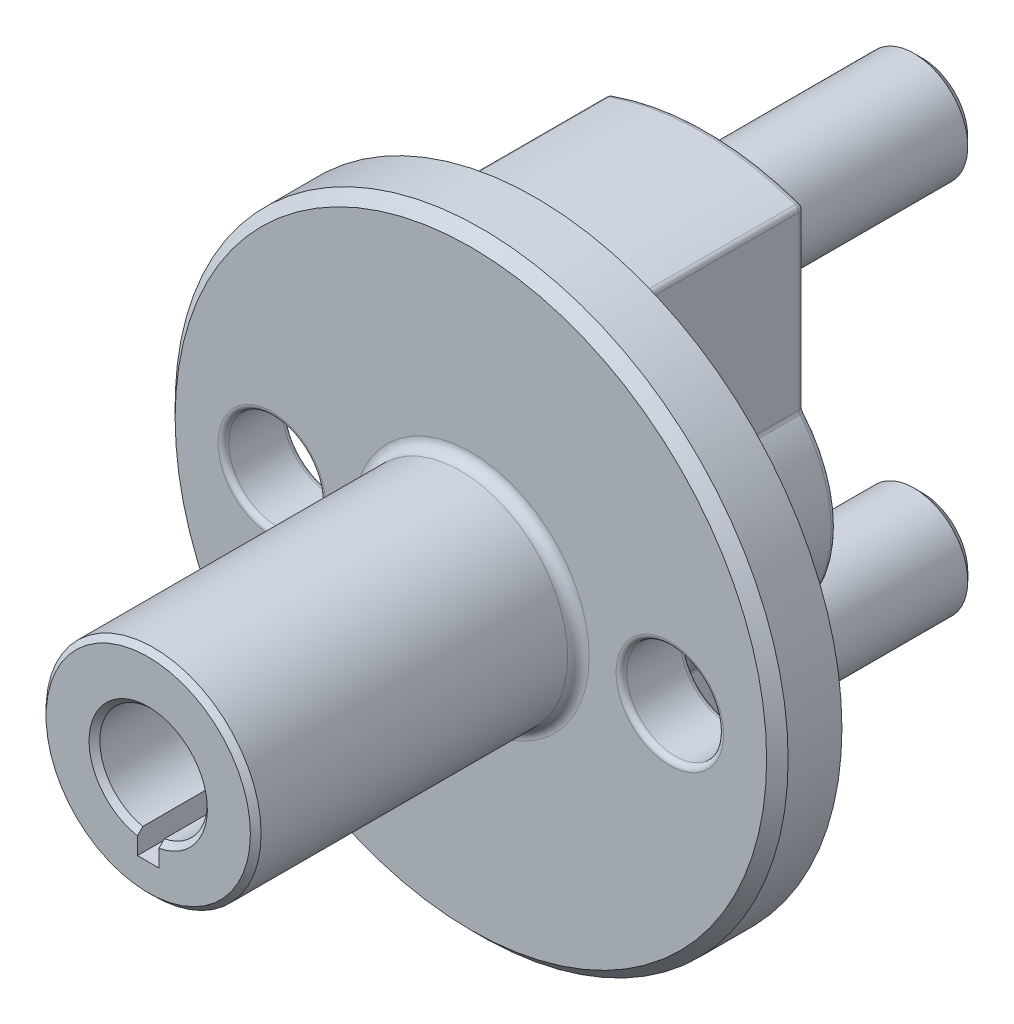
from build123d import *

# Parameters (mm, degrees)
SKETCH1_R           = 28.5
BOSS_EXTRUDE1_DEPTH = 6
BOSS_EXTRUDE2_DEPTH = 16
CHAMFER1_SIZE       = 1
FILLET1_R           = 0.5
SKETCH4_R           = 4.5
CUT_EXTRUDE1_DEPTH  = 23.0000001
FILLET2_R           = 0.5
SKETCH5_R           = 10
BOSS_EXTRUDE3_DEPTH = 30
FILLET3_R           = 1
CHAMFER2_SIZE       = 0.5
SKETCH6_R           = 5
BOSS_EXTRUDE4_DEPTH = 20
CHAMFER3_SIZE       = 0.8
CUT_EXTRUDE2_DEPTH  = 30
CHAMFER4_SIZE       = 0.5


with BuildPart() as part:
    # Sketch1 → Boss-Extrude1 (new body)
    with BuildSketch(Plane.XY):
        Circle(SKETCH1_R)
    extrude(amount=BOSS_EXTRUDE1_DEPTH)

    # Sketch3 → Boss-Extrude2 (add)
    with BuildSketch(Plane(origin=(0, 0, 0), x_dir=(-1, 0, 0), z_dir=(0, 0, -1))):
        with BuildLine():
            Line((-9, 24.392621835), (-9, 7.937253933))
            ThreePointArc((-9, 7.937253933), (-12, 0), (-9, -7.937253933))
            Line((-9, -7.937253933), (-9, -24.392621835))
            ThreePointArc((-9, -24.392621835), (0, -26), (9, -24.392621835))
            Line((9, -24.392621835), (9, -7.937253933))
            ThreePointArc((9, -7.937253933), (12, 0), (9, 7.937253933))
            Line((9, 7.937253933), (9, 24.392621835))
            ThreePointArc((9, 24.392621835), (0, 26), (-9, 24.392621835))
        make_face()
    extrude(amount=BOSS_EXTRUDE2_DEPTH)

    # Chamfer1
    chamfer1_edges = [part.edges().sort_by_distance(p)[0] for p in [
        (-28.5, 0, 6),
    ]]
    chamfer(chamfer1_edges, length=CHAMFER1_SIZE)

    # Fillet1
    fillet1_edges = [part.edges().sort_by_distance(p)[0] for p in [
        (9, 7.937253933, -8),
        (9, -16.164937884, 0),
        (9, -7.937253933, -8),
        (0, -26, 0),
        (9, -24.392621835, -8),
        (-9, -16.164937884, 0),
        (-9, -24.392621835, -8),
        (-12, 0, 0),
        (-9, -7.937253933, -8),
        (-9, 16.164937884, 0),
        (-9, 7.937253933, -8),
        (0, 26, -16),
        (9, 16.164937884, -16),
        (12, 0, -16),
        (9, -16.164937884, -16),
        (0, -26, -16),
        (-9, -16.164937884, -16),
        (-12, 0, -16),
        (-9, 16.164937884, -16),
        (0, 26, 0),
        (-9, 24.392621835, -8),
        (9, 16.164937884, 0),
        (9, 24.392621835, -8),
        (12, 0, 0),
    ]]
    fillet(fillet1_edges, radius=FILLET1_R)

    # Sketch4 → Cut-Extrude1 (cut, through all)
    with BuildSketch(Plane.XY.offset(6)):
        with Locations((18.5, 0)):
            Circle(SKETCH4_R)
        with Locations((-18.5, 0)):
            Circle(SKETCH4_R)
    extrude(amount=-CUT_EXTRUDE1_DEPTH, mode=Mode.SUBTRACT)

    # Fillet2
    fillet2_edges = [part.edges().sort_by_distance(p)[0] for p in [
        (14, 0, 0),
        (14, 0, 6),
        (-23, 0, 0),
        (-23, 0, 6),
    ]]
    fillet(fillet2_edges, radius=FILLET2_R)

    # Sketch5 → Boss-Extrude3 (add)
    with BuildSketch(Plane.XY.offset(6)):
        Circle(SKETCH5_R)
    extrude(amount=BOSS_EXTRUDE3_DEPTH)

    # Fillet3
    fillet3_edges = [part.edges().sort_by_distance(p)[0] for p in [
        (-10, 0, 6),
    ]]
    fillet(fillet3_edges, radius=FILLET3_R)

    # Chamfer2
    chamfer2_edges = [part.edges().sort_by_distance(p)[0] for p in [
        (-10, 0, 36),
    ]]
    chamfer(chamfer2_edges, length=CHAMFER2_SIZE)

    # Sketch6 → Boss-Extrude4 (add)
    with BuildSketch(Plane(origin=(0, 0, -16), x_dir=(-1, 0, 0), z_dir=(0, 0, -1))):
        with Locations((0, 17.5)):
            Circle(SKETCH6_R)
        with Locations((0, -17.5)):
            Circle(SKETCH6_R)
    extrude(amount=BOSS_EXTRUDE4_DEPTH)

    # Chamfer3
    chamfer3_edges = [part.edges().sort_by_distance(p)[0] for p in [
        (5, 17.5, -36),
        (5, -17.5, -36),
    ]]
    chamfer(chamfer3_edges, length=CHAMFER3_SIZE)

    # Sketch7 → Cut-Extrude2 (cut)
    with BuildSketch(Plane.XY.offset(36)):
        with BuildLine():
            Line((-1, -4.898979486), (-1, -7))
            Line((-1, -7), (1, -7))
            Line((1, -7), (1, -4.898979486))
            ThreePointArc((1, -4.898979486), (0, 5), (-1, -4.898979486))
        make_face()
    extrude(amount=-CUT_EXTRUDE2_DEPTH, mode=Mode.SUBTRACT)

    # Chamfer4
    chamfer4_edges = [part.edges().sort_by_distance(p)[0] for p in [
        (0, 5, 36),
    ]]
    chamfer(chamfer4_edges, length=CHAMFER4_SIZE)


solid = part.part
